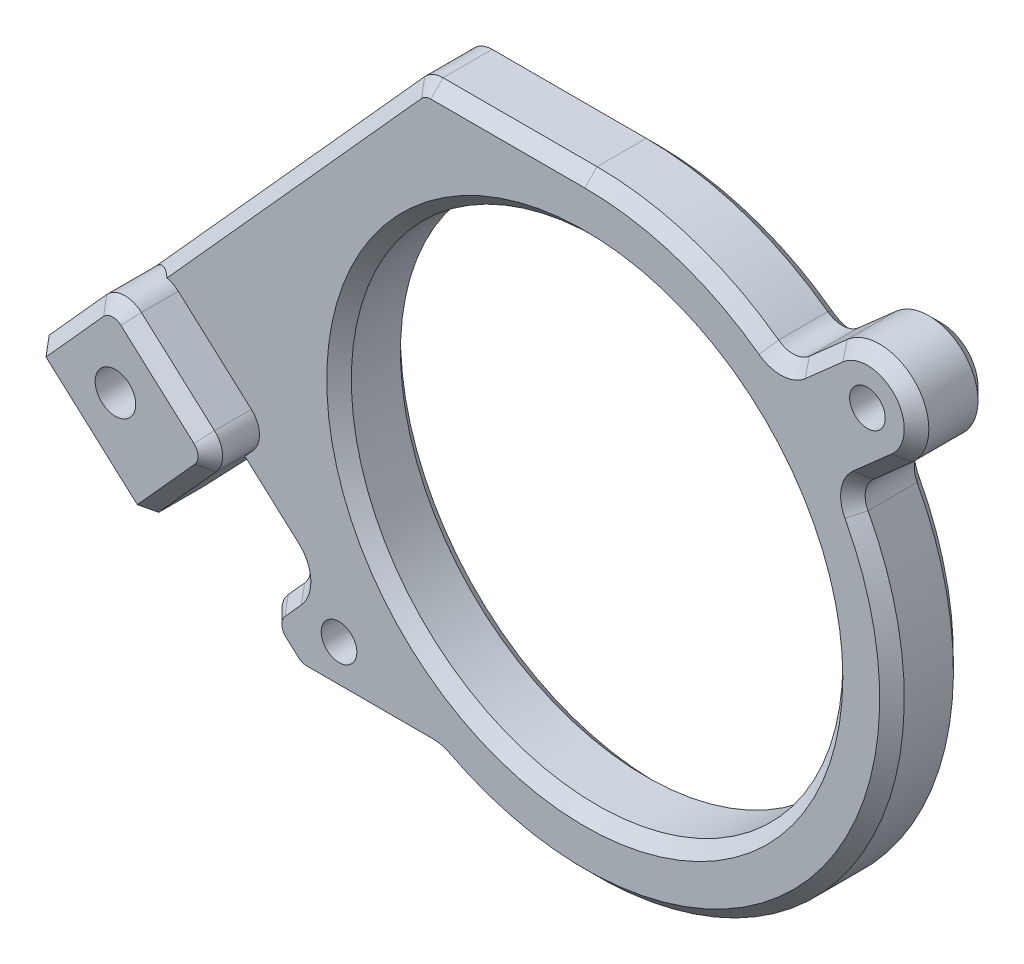
from build123d import *

# Parameters (mm, degrees)
SKETCH_1_W                   = 60
SKETCH_1_H                   = 55
EXTRUDE_1_DEPTH              = 6
HOLE_WIZARD_M4_1_D           = 2.9
HOLE_WIZARD_M4_1_DEPTH       = 10
SKETCH_5_R                   = 20
CUT_EXTRUDE_1_DEPTH          = 7
SKETCH_6_W                   = 60
SKETCH_6_H                   = 55
CUT_EXTRUDE_2_DEPTH          = 7
EXTRUDE_2_DEPTH              = 6
EXTRUDE_3_DEPTH              = 6
EXTRUDE_4_DEPTH              = 4
CUT_EXTRUDE_3_DEPTH          = 11
CUT_EXTRUDE_4_DEPTH          = 6
FILLET_1_R                   = 2
EXTRUDE_5_DEPTH              = 6
CHAMFER_2_SIZE               = 5
FILLET_4_R                   = 2
CHAMFER_3_SIZE               = 1
HOLE_WIZARD_M3_2_D           = 3.3
HOLE_WIZARD_M3_2_DEPTH       = 10
HOLE_WIZARD_M3_2_CBORE_D     = 6.5
HOLE_WIZARD_M3_2_CBORE_DEPTH = 3.4
HOLE_WIZARD_M3_2_TIP         = 0.991420021


with BuildPart() as part:
    # ｽｹｯﾁ1 → ﾎﾞｽ - 押し出し1 (new body)
    with BuildSketch(Plane.XY):
        Rectangle(SKETCH_1_W, SKETCH_1_H)
    extrude(amount=EXTRUDE_1_DEPTH)

    # M4 すきま穴1
    with Locations(Plane.XY.offset(6)):
        with Locations((-20, -18), (23, 20)):
            Hole(HOLE_WIZARD_M4_1_D / 2, depth=HOLE_WIZARD_M4_1_DEPTH)

    # ｽｹｯﾁ5 → ｶｯﾄ - 押し出し1 (cut, through all)
    with BuildSketch(Plane.XY.offset(6)):
        Circle(SKETCH_5_R)
    extrude(amount=-CUT_EXTRUDE_1_DEPTH, mode=Mode.SUBTRACT)

    # ｽｹｯﾁ6 → ｶｯﾄ - 押し出し2 (cut, through all)
    with BuildSketch(Plane.XY.offset(6)):
        Rectangle(SKETCH_6_W, SKETCH_6_H)
        with BuildLine():
            ThreePointArc((-17.351208814, -20.997316342), (-22.997316342, -20.648791186), (-22.648791186, -15.002683658))
            Line((-22.648791186, -15.002683658), (-21.007829355, -13.552531342))
            ThreePointArc((-21.007829355, -13.552531342), (-16.554944912, 18.733227137), (16.03335661, 19.181539975))
            Line((16.03335661, 19.181539975), (20.351208814, 22.997316342))
            ThreePointArc((20.351208814, 22.997316342), (25.997316342, 22.648791186), (25.648791186, 17.002683658))
            Line((25.648791186, 17.002683658), (21.271672672, 13.134532414))
            ThreePointArc((21.271672672, 13.134532414), (24.04986296, 6.826718948), (25, 0))
            ThreePointArc((25, 0), (10.810307191, -22.541900062), (-15.650980674, -19.494789148))
            Line((-15.650980674, -19.494789148), (-17.351208814, -20.997316342))
        make_face(mode=Mode.SUBTRACT)
    extrude(amount=-CUT_EXTRUDE_2_DEPTH, mode=Mode.SUBTRACT)

    # ｽｹｯﾁ7 → ﾎﾞｽ - 押し出し2 (add)
    with BuildSketch(Plane.XY.offset(6)):
        with BuildLine():
            Line((0, 25), (-21.5, 25))
            Line((-21.5, 25), (-21.5, 12.757350822))
            ThreePointArc((-21.5, 12.757350822), (-12.370655388, 21.724798855), (0, 25))
        make_face()
        with BuildLine():
            ThreePointArc((-17.351208814, -20.997316342), (-18.583890076, -21.74094008), (-20, -22))
            Line((-20, -22), (-11.874342087, -22))
            ThreePointArc((-11.874342087, -22), (-13.819546614, -20.833149819), (-15.650980674, -19.494789148))
            Line((-15.650980674, -19.494789148), (-17.351208814, -20.997316342))
        make_face()
        with BuildLine():
            ThreePointArc((-21.007829355, -13.552531342), (-21.25763315, -13.157242601), (-21.5, -12.757350822))
            Line((-21.5, -12.757350822), (-21.5, -13.987472843))
            Line((-21.5, -13.987472843), (-21.007829355, -13.552531342))
        make_face()
    extrude(amount=-EXTRUDE_2_DEPTH)

    # ｽｹｯﾁ8 → ﾎﾞｽ - 押し出し3 (add)
    with BuildSketch(Plane.XY.offset(6)):
        with BuildLine():
            Line((-21.5, 12.757350822), (-21.5, 25))
            Line((-21.5, 25), (-45.717384076, -1.896129831))
            Line((-45.717384076, -1.896129831), (-23.389774269, -22))
            Line((-23.389774269, -22), (-20, -22))
            ThreePointArc((-20, -22), (-23.74094008, -19.416109924), (-22.648791186, -15.002683658))
            Line((-22.648791186, -15.002683658), (-21.5, -13.987472843))
            Line((-21.5, -13.987472843), (-21.5, -12.757350822))
            ThreePointArc((-21.5, -12.757350822), (-25, 0), (-21.5, 12.757350822))
        make_face()
    extrude(amount=-EXTRUDE_3_DEPTH)

    # ｽｹｯﾁ9 → ﾎﾞｽ - 押し出し4 (add)
    with BuildSketch(Plane(origin=(0, 0, 0), x_dir=(-1, 0, 0), z_dir=(0, 0, -1))):
        Polygon((25.649471154, -6.509032491), (32.340777217, -13.940480745), (45.717384076, -1.896129831), (39.026078012, 5.535318424), align=None)
    extrude(amount=EXTRUDE_4_DEPTH)

    # ｽｹｯﾁ10 → ｶｯﾄ - 押し出し3 (cut, through all)
    with BuildSketch(Plane(origin=(0, 0, -4), x_dir=(-1, 0, 0), z_dir=(0, 0, -1))):
        Polygon((39.026078012, 5.535318424), (21.5, 25), (13.426203622, 25), (41.258515123, -5.910913469), (45.717384076, -1.896129831), align=None)
    extrude(amount=-CUT_EXTRUDE_3_DEPTH, mode=Mode.SUBTRACT)

    # ｽｹｯﾁ12 → ｶｯﾄ - 押し出し4 (cut)
    with BuildSketch(Plane.XY.offset(6)):
        Polygon((-41.258515123, -5.910913469), (-26.47934628, -19.218136867), (-22.464562642, -14.759267914), (-37.243731485, -1.452044516), align=None)
    extrude(amount=-CUT_EXTRUDE_4_DEPTH, mode=Mode.SUBTRACT)

    # ﾌｨﾚｯﾄ1
    fillet_1_edges = [part.edges().sort_by_distance(p)[0] for p in [
        (-25.649471154, -6.509032491, -2),
        (-34.567209059, 1.520534786, -2),
        (-26.47934628, -19.218136867, 3),
    ]]
    fillet(fillet_1_edges, radius=FILLET_1_R)

    # ｽｹｯﾁ13 → ﾎﾞｽ - 押し出し5 (add)
    with BuildSketch(Plane.XY):
        Polygon((-32.340777217, -13.940480745), (-28.325993579, -9.481611793), (-37.243731485, -1.452044516), (-41.258515123, -5.910913469), align=None)
    extrude(amount=EXTRUDE_5_DEPTH)

    # 面取り2
    chamfer_2_edges = [part.edges().sort_by_distance(p)[0] for p in [
        (-36.79964617, -9.925697107, 6),
    ]]
    chamfer(chamfer_2_edges, length=CHAMFER_2_SIZE)

    # ﾌｨﾚｯﾄ4
    fillet_4_edges = [part.edges().sort_by_distance(p)[0] for p in [
        (-23.389774269, -22, 3),
        (-13.426203622, 25, 3),
        (-22.464562642, -14.759267914, 3),
        (-33.453993138, -6.20997298, 6),
        (-36.79964617, -9.925697107, 1),
        (21.271672672, 13.134532414, 3),
        (16.03335661, 19.181539975, 3),
        (-11.874342087, -22, 3),
    ]]
    fillet(fillet_4_edges, radius=FILLET_4_R)

    # 面取り3
    chamfer_3_edges = [part.edges().sort_by_distance(p)[0] for p in [
        (-29.664254792, -10.967901443, -4),
        (-32.340777217, -13.940480745, -1.914213562),
        (-36.79964617, -9.925697107, -4),
        (-38.581992697, -2.938334167, -4),
        (-30.108340106, -2.494248852, -4),
        (-34.523852534, 0.693242992, -4),
        (-26.476762948, -6.552389016, -4),
        (-24.471954461, -16.98870239, 6),
        (-24.471954461, -16.98870239, 0),
        (-24.47668202, -21.021343865, 6),
        (-25.652054486, -19.174780341, 6),
        (-25.652054486, -19.174780341, 0),
        (-24.47668202, -21.021343865, 0),
        (-25.690286025, 11.379356601, 6),
        (-28.38339591, -9.54536354, 6),
        (-26.138422936, -11.451309247, 6),
        (-17.495681538, -22, 6),
        (17.805324329, -17.549086174, 6),
        (24.071292776, 15.608615296, 6),
        (18.815379015, 21.640071403, 6),
        (7.771710455, 23.761323966, 6),
        (-13.349219538, 24.827090915, 6),
        (-23.338782098, -21.867160853, 6),
        (-17.495681538, -22, 0),
        (-26.138422936, -11.451309247, 0),
        (-24.963753087, 12.186253174, 0),
        (-6.267873126, 25, 0),
        (7.771710455, 23.761323966, 0),
        (18.815379015, 21.640071403, 0),
        (24.071292776, 15.608615296, 0),
        (17.805324329, -17.549086174, 0),
        (-13.349219538, 24.827090915, 0),
        (-23.338782098, -21.867160853, 0),
        (-41.258515123, -5.910913469, -1.914213562),
        (-39.585688607, -4.053051405, 3.5),
        (-37.870666541, -2.148326436, 5.847759065),
        (-41.156646054, -5.797776406, 0.93693974),
        (-30.667950701, -12.082618682, 3.5),
        (-28.952928635, -10.177893712, 5.847759065),
        (-32.238908148, -13.827343682, 0.93693974),
        (21.8499093, 13.07067214, 0),
        (21.8499093, 13.07067214, 6),
        (16.046656493, 19.783578925, 0),
        (16.046656493, 19.783578925, 6),
        (-11.897912356, -22.056349368, 6),
        (-11.897912356, -22.056349368, 0),
        (-23.291854436, -14.80262444, 6),
        (-23.291854436, -14.80262444, 0),
        (-20, 0, 0),
        (-20, 0, 6),
        (25.997316342, 22.648791186, 0),
        (25.997316342, 22.648791186, 6),
        (-6.267873126, 25, 6),
    ]]
    chamfer(chamfer_3_edges, length=CHAMFER_3_SIZE)

    # M3 六角穴付き頭ねじ用座ぐり穴2
    with Locations(Plane.XY.offset(6)):
        with Locations((-34.197137964, -5.540842373)):
            CounterBoreHole(HOLE_WIZARD_M3_2_D / 2, HOLE_WIZARD_M3_2_CBORE_D / 2, HOLE_WIZARD_M3_2_CBORE_DEPTH, depth=HOLE_WIZARD_M3_2_DEPTH)
            with Locations((0, 0, -(HOLE_WIZARD_M3_2_DEPTH + HOLE_WIZARD_M3_2_TIP / 2))):  # 118° drill point
                Cone(0, HOLE_WIZARD_M3_2_D / 2, HOLE_WIZARD_M3_2_TIP, mode=Mode.SUBTRACT)


with BuildPart() as body_2:
    # ﾐﾗｰ1: mirrored copy
    add(part.part.mirror(Plane(origin=(0, 0, -4), x_dir=(1, 0, 0), z_dir=(0, 0, -1))))


solid = body_2.part
